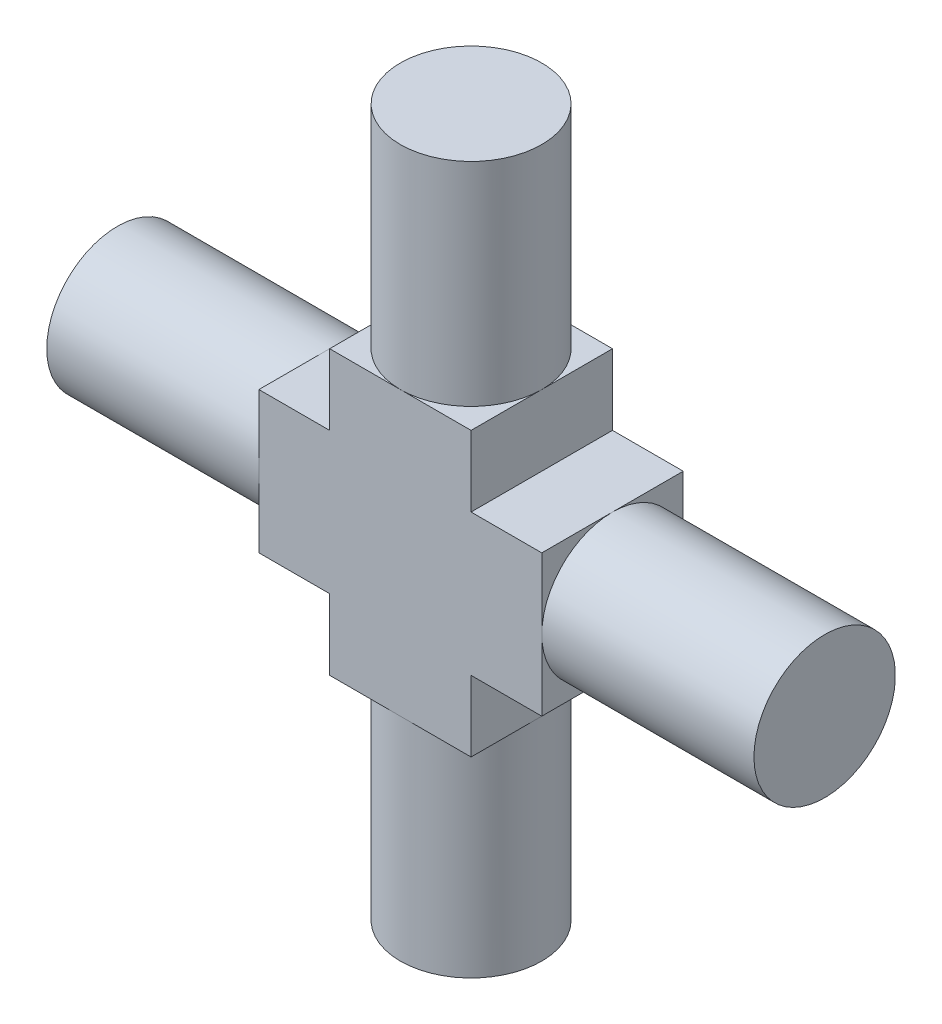
from build123d import *

# Parameters (mm, degrees)
BOSS_EXTRUDE1_DEPTH = 5
SKETCH2_R           = 2.5
BOSS_EXTRUDE2_DEPTH = 7.5
CIRPATTERN1_COUNT   = 4


with BuildPart() as part:
    # Sketch1 → Boss-Extrude1 (new body)
    with BuildSketch(Plane.XY):
        Polygon((-2.5, 2.5), (-5, 2.5), (-5, -2.5), (-2.5, -2.5), (-2.5, -5), (2.5, -5), (2.5, -2.5), (5, -2.5), (5, 2.5), (2.5, 2.5), (2.5, 5), (-2.5, 5), align=None)
    extrude(amount=BOSS_EXTRUDE1_DEPTH)

    # Sketch2 → Boss-Extrude2 (add)
    with BuildSketch(Plane(origin=(0, 5, 0), x_dir=(1, 0, 0), z_dir=(0, 1, 0))):
        with Locations((0, -2.5)):
            Circle(SKETCH2_R)
    boss_extrude2 = extrude(amount=BOSS_EXTRUDE2_DEPTH)

    # CirPattern1: Boss-Extrude2 ×4 about axis
    cirpattern1_axis = Axis((0, 0, 0), (0, 0, 1))
    for i in range(1, CIRPATTERN1_COUNT):
        add(boss_extrude2.rotate(cirpattern1_axis, i * 360 / CIRPATTERN1_COUNT))


solid = part.part
